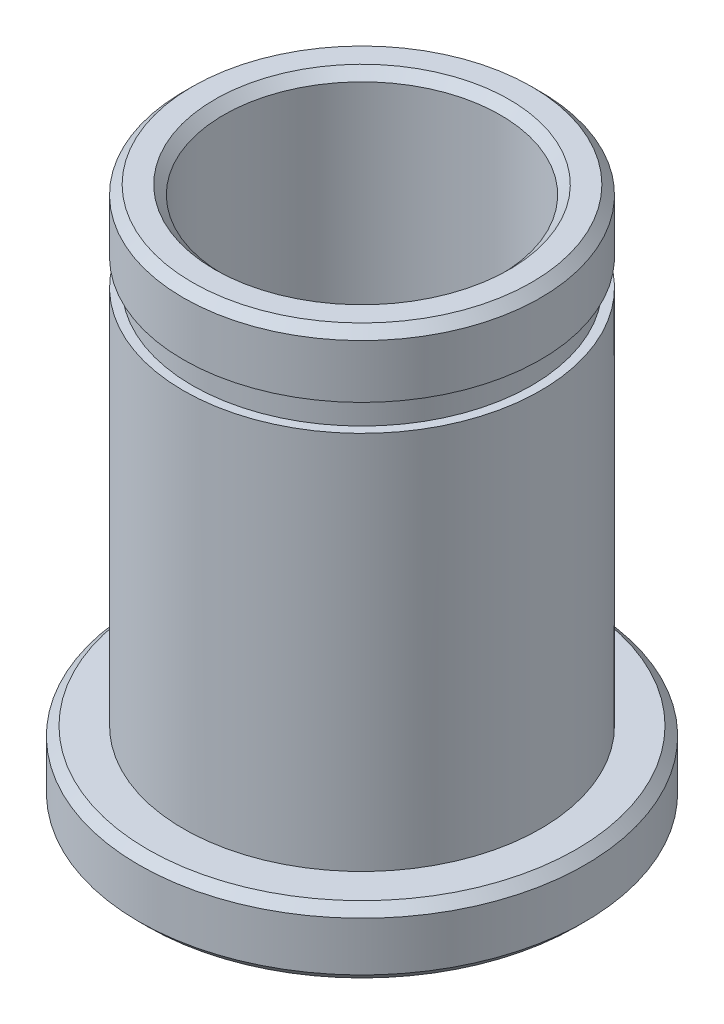
from build123d import *

# Parameters (mm, degrees)
SKETCH1_R           = 8
BOSS_EXTRUDE1_DEPTH = 24
SKETCH2_R           = 10
BOSS_EXTRUDE2_DEPTH = 3
SKETCH4_R           = 8
SKETCH4_R_2         = 7.6
CUT_EXTRUDE1_DEPTH  = 1.2
SKETCH5_R           = 6.2
CUT_EXTRUDE2_DEPTH  = 25
CHAMFER1_SIZE       = 0.4
CHAMFER2_SIZE       = 0.4


with BuildPart() as part:
    # Sketch1 → Boss-Extrude1 (new body)
    with BuildSketch(Plane(origin=(0, 0, 0), x_dir=(1, 0, 0), z_dir=(0, 1, 0))):
        Circle(SKETCH1_R)
    extrude(amount=BOSS_EXTRUDE1_DEPTH)

    # Sketch2 → Boss-Extrude2 (add)
    with BuildSketch(Plane.XZ):
        Circle(SKETCH2_R)
    extrude(amount=-BOSS_EXTRUDE2_DEPTH)

    # Sketch4 → Cut-Extrude1 (cut)
    with BuildSketch(Plane(origin=(0, 20, 0), x_dir=(1, 0, 0), z_dir=(0, 1, 0))):
        Circle(SKETCH4_R)
        Circle(SKETCH4_R_2, mode=Mode.SUBTRACT)
    extrude(amount=CUT_EXTRUDE1_DEPTH, mode=Mode.SUBTRACT)

    # Sketch5 → Cut-Extrude2 (cut, through all)
    with BuildSketch(Plane.XZ):
        Circle(SKETCH5_R)
    extrude(amount=-CUT_EXTRUDE2_DEPTH, mode=Mode.SUBTRACT)

    # Chamfer1
    chamfer1_edges = [part.edges().sort_by_distance(p)[0] for p in [
        (-6.2, 24, 0),
        (-6.2, 0, 0),
    ]]
    chamfer(chamfer1_edges, length=CHAMFER1_SIZE)

    # Chamfer2
    chamfer2_edges = [part.edges().sort_by_distance(p)[0] for p in [
        (-8, 24, 0),
        (-10, 3, 0),
        (-10, 0, 0),
    ]]
    chamfer(chamfer2_edges, length=CHAMFER2_SIZE)


solid = part.part
